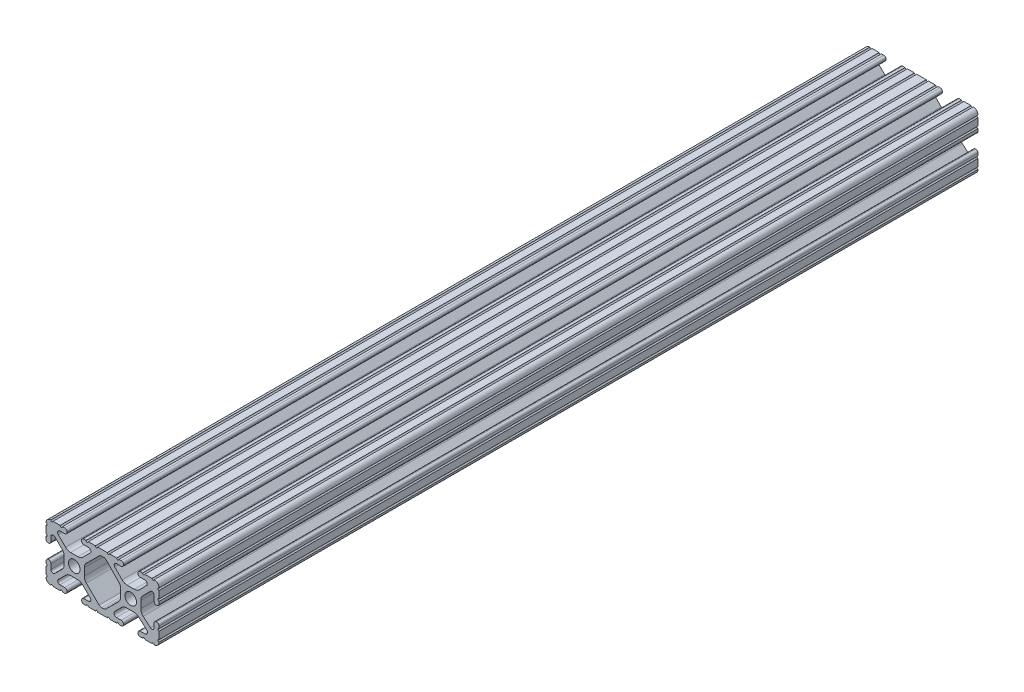
from build123d import *

# Parameters (mm, degrees)
SKETCH1_R               = 2.6035
BOSS_EXTRUDE1_DEPTH     = 184.15
SKETCH2_R               = 3.175
CUT_EXTRUDE1_DEPTH      = 9.191498123
CUT_EXTRUDE1_DEPTH_BACK = 43.608501877


with BuildPart() as part:
    # Sketch1 → Boss-Extrude1 (new body, symmetric)
    with BuildSketch(Plane.XY):
        with BuildLine():
            Line((18.01710265, 12.7), (16.98745015, 12.7))
            ThreePointArc((16.98745015, 12.7), (16.245730386, 12.392769614), (15.9385, 11.65104985))
            Line((15.9385, 11.65104985), (15.9385, 11.53922))
            ThreePointArc((15.9385, 11.53922), (16.245750844, 10.797450844), (16.98752, 10.4902))
            Line((16.98752, 10.4902), (19.116384363, 10.4902))
            ThreePointArc((19.116384363, 10.4902), (20.052502933, 9.869096983), (19.844087081, 8.765172272))
            Line((19.844087081, 8.765172272), (16.618993479, 5.455112286))
            ThreePointArc((16.618993479, 5.455112286), (15.578994274, 4.745442459), (14.344932584, 4.4958))
            Line((14.344932584, 4.4958), (11.083317835, 4.4958))
            ThreePointArc((11.083317835, 4.4958), (9.854330953, 4.743306833), (8.816955189, 5.447238587))
            Line((8.816955189, 5.447238587), (5.564154119, 8.762652677))
            ThreePointArc((5.564154119, 8.762652677), (5.352591412, 9.867473037), (6.289393385, 10.4902))
            Line((6.289393385, 10.4902), (8.41248, 10.4902))
            ThreePointArc((8.41248, 10.4902), (9.154249156, 10.797450844), (9.4615, 11.53922))
            Line((9.4615, 11.53922), (9.4615, 11.65104985))
            ThreePointArc((9.4615, 11.65104985), (9.154269614, 12.392769614), (8.41254985, 12.7))
            Line((8.41254985, 12.7), (7.38288465, 12.7))
            ThreePointArc((7.38288465, 12.7), (6.87488465, 12.192), (6.36688465, 12.7))
            Line((6.36688465, 12.7), (3.14958095, 12.7))
            ThreePointArc((3.14958095, 12.7), (2.64158095, 12.192), (2.13358095, 12.7))
            Line((2.13358095, 12.7), (-2.13358095, 12.7))
            ThreePointArc((-2.13358095, 12.7), (-2.64158095, 12.192), (-3.14958095, 12.7))
            Line((-3.14958095, 12.7), (-6.36689735, 12.7))
            ThreePointArc((-6.36689735, 12.7), (-6.87489735, 12.192), (-7.38289735, 12.7))
            Line((-7.38289735, 12.7), (-8.41254985, 12.7))
            ThreePointArc((-8.41254985, 12.7), (-9.154269614, 12.392769614), (-9.4615, 11.65104985))
            Line((-9.4615, 11.65104985), (-9.4615, 11.53922))
            ThreePointArc((-9.4615, 11.53922), (-9.154249156, 10.797450844), (-8.41248, 10.4902))
            Line((-8.41248, 10.4902), (-6.283641037, 10.4902))
            ThreePointArc((-6.283641037, 10.4902), (-5.297291557, 9.829633109), (-5.532576693, 8.666071843))
            Line((-5.532576693, 8.666071843), (-8.809985098, 5.416263103))
            ThreePointArc((-8.809985098, 5.416263103), (-9.836720513, 4.734920264), (-11.045536121, 4.4958))
            Line((-11.045536121, 4.4958), (-14.354463879, 4.4958))
            ThreePointArc((-14.354463879, 4.4958), (-15.563279487, 4.734920264), (-16.590014902, 5.416263103))
            Line((-16.590014902, 5.416263103), (-19.867423307, 8.666071843))
            ThreePointArc((-19.867423307, 8.666071843), (-20.102708443, 9.829633109), (-19.116358963, 10.4902))
            Line((-19.116358963, 10.4902), (-16.98752, 10.4902))
            ThreePointArc((-16.98752, 10.4902), (-16.245750844, 10.797450844), (-15.9385, 11.53922))
            Line((-15.9385, 11.53922), (-15.9385, 11.65104985))
            ThreePointArc((-15.9385, 11.65104985), (-16.245730386, 12.392769614), (-16.98745015, 12.7))
            Line((-16.98745015, 12.7), (-18.01711535, 12.7))
            ThreePointArc((-18.01711535, 12.7), (-18.52511535, 12.192), (-19.03311535, 12.7))
            Line((-19.03311535, 12.7), (-22.2504, 12.7))
            ThreePointArc((-22.2504, 12.7), (-22.758323491, 12.192000006), (-23.266399977, 12.699846982))
            ThreePointArc((-23.266399977, 12.699846982), (-24.782522516, 12.082522516), (-25.399846982, 10.566399977))
            ThreePointArc((-25.399846982, 10.566399977), (-24.892000006, 10.058323491), (-25.4, 9.5504))
            Line((-25.4, 9.5504), (-25.4, 6.3330836))
            ThreePointArc((-25.4, 6.3330836), (-24.892, 5.8250836), (-25.4, 5.3170836))
            Line((-25.4, 5.3170836), (-25.4, 4.237520184))
            ThreePointArc((-25.4, 4.237520184), (-25.107393763, 3.531106237), (-24.400979816, 3.2385))
            Line((-24.400979816, 3.2385), (-24.23922, 3.2385))
            ThreePointArc((-24.23922, 3.2385), (-23.497450844, 3.545750844), (-23.1902, 4.28752))
            Line((-23.1902, 4.28752), (-23.1902, 6.334741132))
            ThreePointArc((-23.1902, 6.334741132), (-22.556026952, 7.286023527), (-21.434002553, 7.066535717))
            Line((-21.434002553, 7.066535717), (-18.147950853, 3.808156468))
            ThreePointArc((-18.147950853, 3.808156468), (-17.452759693, 2.774838327), (-17.208501877, 1.553619571))
            Line((-17.208501877, 1.553619571), (-17.208501877, -1.695179196))
            ThreePointArc((-17.208501877, -1.695179196), (-17.450738657, -2.911536421), (-18.140486065, -3.942289578))
            Line((-18.140486065, -3.942289578), (-21.431579576, -7.227386226))
            ThreePointArc((-21.431579576, -7.227386226), (-22.55444896, -7.449940594), (-23.1902, -6.498002195))
            Line((-23.1902, -6.498002195), (-23.1902, -4.28752))
            ThreePointArc((-23.1902, -4.28752), (-23.497450844, -3.545750844), (-24.23922, -3.2385))
            Line((-24.23922, -3.2385), (-24.35098, -3.2385))
            ThreePointArc((-24.35098, -3.2385), (-25.092749156, -3.545750844), (-25.4, -4.28752))
            Line((-25.4, -4.28752), (-25.4, -5.3171344))
            ThreePointArc((-25.4, -5.3171344), (-24.892, -5.8251344), (-25.4, -6.3331344))
            Line((-25.4, -6.3331344), (-25.4, -9.5504))
            ThreePointArc((-25.4, -9.5504), (-24.892000006, -10.058323491), (-25.399846982, -10.566399977))
            ThreePointArc((-25.399846982, -10.566399977), (-24.782522516, -12.082522516), (-23.266399977, -12.699846982))
            ThreePointArc((-23.266399977, -12.699846982), (-22.758323491, -12.192000006), (-22.2504, -12.7))
            Line((-22.2504, -12.7), (-19.03308995, -12.7))
            ThreePointArc((-19.03308995, -12.7), (-18.52508995, -12.192), (-18.01708995, -12.7))
            Line((-18.01708995, -12.7), (-16.9874692, -12.7))
            ThreePointArc((-16.9874692, -12.7), (-16.245700044, -12.392749156), (-15.9384492, -11.65098))
            Line((-15.9384492, -11.65098), (-15.9384492, -11.53922))
            ThreePointArc((-15.9384492, -11.53922), (-16.245700044, -10.797450844), (-16.9874692, -10.4902))
            Line((-16.9874692, -10.4902), (-19.116358963, -10.4902))
            ThreePointArc((-19.116358963, -10.4902), (-20.055197748, -9.862578342), (-19.834124023, -8.755124678))
            Line((-19.834124023, -8.755124678), (-16.49660751, -5.423689618))
            ThreePointArc((-16.49660751, -5.423689618), (-15.467274017, -4.736928798), (-14.253591699, -4.4958))
            Line((-14.253591699, -4.4958), (-11.146408301, -4.4958))
            ThreePointArc((-11.146408301, -4.4958), (-9.932725983, -4.736928798), (-8.90339249, -5.423689618))
            Line((-8.90339249, -5.423689618), (-5.565875977, -8.755124678))
            ThreePointArc((-5.565875977, -8.755124678), (-5.344802252, -9.862578342), (-6.283641037, -10.4902))
            Line((-6.283641037, -10.4902), (-8.4125308, -10.4902))
            ThreePointArc((-8.4125308, -10.4902), (-9.154299956, -10.797450844), (-9.4615508, -11.53922))
            Line((-9.4615508, -11.53922), (-9.4615508, -11.65098))
            ThreePointArc((-9.4615508, -11.65098), (-9.154299956, -12.392749156), (-8.4125308, -12.7))
            Line((-8.4125308, -12.7), (-7.38287195, -12.7))
            ThreePointArc((-7.38287195, -12.7), (-6.87487195, -12.192), (-6.36687195, -12.7))
            Line((-6.36687195, -12.7), (-3.14960635, -12.7))
            ThreePointArc((-3.14960635, -12.7), (-2.64160635, -12.192), (-2.13360635, -12.7))
            Line((-2.13360635, -12.7), (2.13360635, -12.7))
            ThreePointArc((2.13360635, -12.7), (2.64159365, -12.1920127), (3.14958095, -12.7))
            Line((3.14958095, -12.7), (6.36691005, -12.7))
            ThreePointArc((6.36691005, -12.7), (6.87491005, -12.192), (7.38291005, -12.7))
            Line((7.38291005, -12.7), (8.4125308, -12.7))
            ThreePointArc((8.4125308, -12.7), (9.154299956, -12.392749156), (9.4615508, -11.65098))
            Line((9.4615508, -11.65098), (9.4615508, -11.53922))
            ThreePointArc((9.4615508, -11.53922), (9.154299956, -10.797450844), (8.4125308, -10.4902))
            Line((8.4125308, -10.4902), (6.289393385, -10.4902))
            ThreePointArc((6.289393385, -10.4902), (5.231590322, -9.783049717), (5.480677245, -8.535265862))
            Line((5.480677245, -8.535265862), (8.597933595, -5.423689618))
            ThreePointArc((8.597933595, -5.423689618), (9.627267088, -4.736928798), (10.840949406, -4.4958))
            Line((10.840949406, -4.4958), (14.102564155, -4.4958))
            ThreePointArc((14.102564155, -4.4958), (15.215927525, -4.697410182), (16.187895372, -5.276636531))
            Line((16.187895372, -5.276636531), (19.868247549, -8.482246082))
            ThreePointArc((19.868247549, -8.482246082), (20.188435806, -9.746879864), (19.116384363, -10.4902))
            Line((19.116384363, -10.4902), (16.9874692, -10.4902))
            ThreePointArc((16.9874692, -10.4902), (16.245700044, -10.797450844), (15.9384492, -11.53922))
            Line((15.9384492, -11.53922), (15.9384492, -11.65098))
            ThreePointArc((15.9384492, -11.65098), (16.245700044, -12.392749156), (16.9874692, -12.7))
            Line((16.9874692, -12.7), (18.01710265, -12.7))
            ThreePointArc((18.01710265, -12.7), (18.52510265, -12.192), (19.03310265, -12.7))
            Line((19.03310265, -12.7), (22.2504, -12.7))
            ThreePointArc((22.2504, -12.7), (22.758323491, -12.192000006), (23.266399977, -12.699846982))
            ThreePointArc((23.266399977, -12.699846982), (24.782522516, -12.082522516), (25.399846982, -10.566399977))
            ThreePointArc((25.399846982, -10.566399977), (24.892000006, -10.058323492), (25.4, -9.550400001))
            Line((25.4, -9.550400001), (25.4, -6.333083592))
            ThreePointArc((25.4, -6.333083592), (24.892000001, -5.825083593), (25.4, -5.317083593))
            Line((25.4, -5.317083593), (25.4, -4.237520184))
            ThreePointArc((25.4, -4.237520184), (25.107393763, -3.531106237), (24.400979816, -3.2385))
            Line((24.400979816, -3.2385), (24.189220184, -3.2385))
            ThreePointArc((24.189220184, -3.2385), (23.482806237, -3.531106237), (23.1902, -4.237520184))
            Line((23.1902, -4.237520184), (23.1902, -6.155876159))
            ThreePointArc((23.1902, -6.155876159), (22.62232736, -7.038258539), (21.583974541, -6.886926384))
            Line((21.583974541, -6.886926384), (18.29817066, -4.024970844))
            ThreePointArc((18.29817066, -4.024970844), (17.493730985, -2.946044689), (17.208501877, -1.630807374))
            Line((17.208501877, -1.630807374), (17.208501877, 1.630807374))
            ThreePointArc((17.208501877, 1.630807374), (17.442348332, 2.82673414), (18.109440981, 3.846495088))
            Line((18.109440981, 3.846495088), (21.526346532, 7.353420386))
            ThreePointArc((21.526346532, 7.353420386), (22.585896263, 7.574939077), (23.1902, 6.676867167))
            Line((23.1902, 6.676867167), (23.1902, 4.237520184))
            ThreePointArc((23.1902, 4.237520184), (23.482806237, 3.531106237), (24.189220184, 3.2385))
            Line((24.189220184, 3.2385), (24.400979816, 3.2385))
            ThreePointArc((24.400979816, 3.2385), (25.107393763, 3.531106237), (25.4, 4.237520184))
            Line((25.4, 4.237520184), (25.4, 5.3170836))
            ThreePointArc((25.4, 5.3170836), (24.891949193, 5.825134407), (25.4, 6.333185215))
            Line((25.4, 6.333185215), (25.4, 9.550400015))
            ThreePointArc((25.4, 9.550400015), (24.892000013, 10.058323498), (25.399846982, 10.566399977))
            ThreePointArc((25.399846982, 10.566399977), (24.782522516, 12.082522516), (23.266399977, 12.699846982))
            ThreePointArc((23.266399977, 12.699846982), (22.758323491, 12.192000006), (22.2504, 12.7))
            Line((22.2504, 12.7), (19.03310265, 12.7))
            ThreePointArc((19.03310265, 12.7), (18.52510265, 12.192), (18.01710265, 12.7))
        make_face()
        with Locations((-12.7, 0)):
            Circle(SKETCH1_R, mode=Mode.SUBTRACT)
        with Locations((12.7, 0)):
            Circle(SKETCH1_R, mode=Mode.SUBTRACT)
        with BuildLine():
            Line((-7.259513935, -3.869413038), (-1.545748891, -9.572766749))
            ThreePointArc((-1.545748891, -9.572766749), (-1.035199478, -9.913400116), (-0.433213048, -10.033))
            Line((-0.433213048, -10.033), (0.433213048, -10.033))
            ThreePointArc((0.433213048, -10.033), (1.035199478, -9.913400116), (1.545748891, -9.572766749))
            Line((1.545748891, -9.572766749), (7.259513935, -3.869413038))
            ThreePointArc((7.259513935, -3.869413038), (7.949261343, -2.838659881), (8.191498123, -1.622302656))
            Line((8.191498123, -1.622302656), (8.191498123, 1.622302656))
            ThreePointArc((8.191498123, 1.622302656), (7.955573352, 2.823327967), (7.282860769, 3.845864069))
            Line((7.282860769, 3.845864069), (1.675572808, 9.561086461))
            ThreePointArc((1.675572808, 9.561086461), (1.161034429, 9.910236611), (0.551456936, 10.033))
            Line((0.551456936, 10.033), (-0.395199982, 10.033))
            ThreePointArc((-0.395199982, 10.033), (-0.994772524, 9.914396349), (-1.50403329, 9.576450301))
            Line((-1.50403329, 9.576450301), (-7.252049147, 3.876839553))
            ThreePointArc((-7.252049147, 3.876839553), (-7.947240307, 2.843521412), (-8.191498123, 1.622302656))
            Line((-8.191498123, 1.622302656), (-8.191498123, -1.622302656))
            ThreePointArc((-8.191498123, -1.622302656), (-7.949261343, -2.838659881), (-7.259513935, -3.869413038))
        make_face(mode=Mode.SUBTRACT)
    extrude(amount=BOSS_EXTRUDE1_DEPTH, both=True)

    # Sketch2 → Cut-Extrude1 (cut, two sides)
    with BuildSketch(Plane(origin=(17.208501877, 0, 0), x_dir=(0, 0, -1), z_dir=(1, 0, 0))) as cut_extrude1_sk:
        with Locations((39.6875, 0)):
            Circle(SKETCH2_R)
        with Locations((65.0875, 0)):
            Circle(SKETCH2_R)
        with Locations((-65.0875, 0)):
            Circle(SKETCH2_R)
        with Locations((-39.6875, 0)):
            Circle(SKETCH2_R)
    extrude(amount=CUT_EXTRUDE1_DEPTH, mode=Mode.SUBTRACT)
    extrude(cut_extrude1_sk.sketch, amount=-CUT_EXTRUDE1_DEPTH_BACK, mode=Mode.SUBTRACT)


solid = part.part
